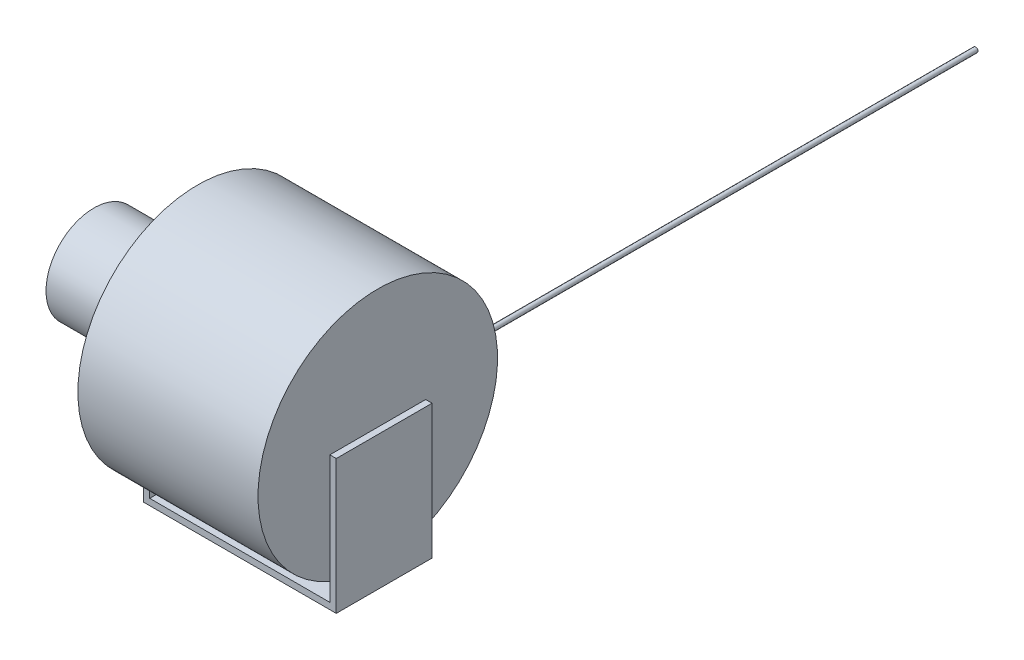
from build123d import *

# Parameters (mm, degrees)
SKETCH1_R           = 187.5
BOSS_EXTRUDE1_DEPTH = 282
SKETCH2_W           = 150
SKETCH2_H           = 210
BOSS_EXTRUDE2_DEPTH = 10
SKETCH3_W           = 150
SKETCH3_H           = 210
BOSS_EXTRUDE3_DEPTH = 10
BOSS_EXTRUDE4_REACH = 294
SKETCH4_W           = 150
SKETCH4_H           = 10
SKETCH5_R           = 75
BOSS_EXTRUDE5_DEPTH = 152.4
SKETCH7_R           = 3.8
SKETCH8_R           = 3.8
BOSS_EXTRUDE6_DEPTH = 967.2


with BuildPart() as part:
    # Sketch1 → Boss-Extrude1 (new body)
    with BuildSketch(Plane(origin=(0, 0, 0), x_dir=(0, 0, -1), z_dir=(1, 0, 0))):
        Circle(SKETCH1_R)
    extrude(amount=BOSS_EXTRUDE1_DEPTH)

    # Sketch2 → Boss-Extrude2 (add)
    with BuildSketch(Plane.ZY):
        with Locations((0, -105)):
            Rectangle(SKETCH2_W, SKETCH2_H)
    extrude(amount=BOSS_EXTRUDE2_DEPTH)

    # Sketch3 → Boss-Extrude3 (add)
    with BuildSketch(Plane(origin=(282, 0, 0), x_dir=(0, 0, -1), z_dir=(1, 0, 0))):
        with Locations((0, -105)):
            Rectangle(SKETCH3_W, SKETCH3_H)
    extrude(amount=BOSS_EXTRUDE3_DEPTH)

    # Sketch4 → Boss-Extrude4 (add, up to next)
    with BuildSketch(Plane(origin=(0, 0, 0), x_dir=(0, 0, -1), z_dir=(1, 0, 0)), mode=Mode.PRIVATE) as boss_extrude4_sk1:
        with Locations((0, -205)):
            Rectangle(SKETCH4_W, SKETCH4_H)
    boss_extrude4_tool1 = extrude(boss_extrude4_sk1.sketch, amount=BOSS_EXTRUDE4_REACH, mode=Mode.PRIVATE) - part.part
    add(boss_extrude4_tool1.solids().sort_by_distance((0, -205, 0))[0])

    # Sketch5 → Boss-Extrude5 (add)
    with BuildSketch(Plane.ZY.offset(10)):
        Circle(SKETCH5_R)
    extrude(amount=BOSS_EXTRUDE5_DEPTH)

    # Sweep1: sweep along a path in Sketch6
    with BuildLine(Plane(origin=(50.7, 0, 0), x_dir=(0, 0, -1), z_dir=(1, 0, 0))) as sweep1_path:
        Line((0, -187.5), (200, -187.5))
    # Sketch7 → Sweep1 (sweep)
    with BuildSketch(Plane(origin=(0, 0, -200), x_dir=(-1, 0, 0), z_dir=(0, 0, -1))):
        with Locations((-50.7, -187.5)):
            Circle(SKETCH7_R)
    sweep(path=sweep1_path.line)

    # Sketch8 → Boss-Extrude6 (add)
    with BuildSketch(Plane(origin=(0, 0, -200), x_dir=(-1, 0, 0), z_dir=(0, 0, -1))):
        with Locations((-50.7, -187.5)):
            Circle(SKETCH8_R)
    extrude(amount=BOSS_EXTRUDE6_DEPTH)


solid = part.part
